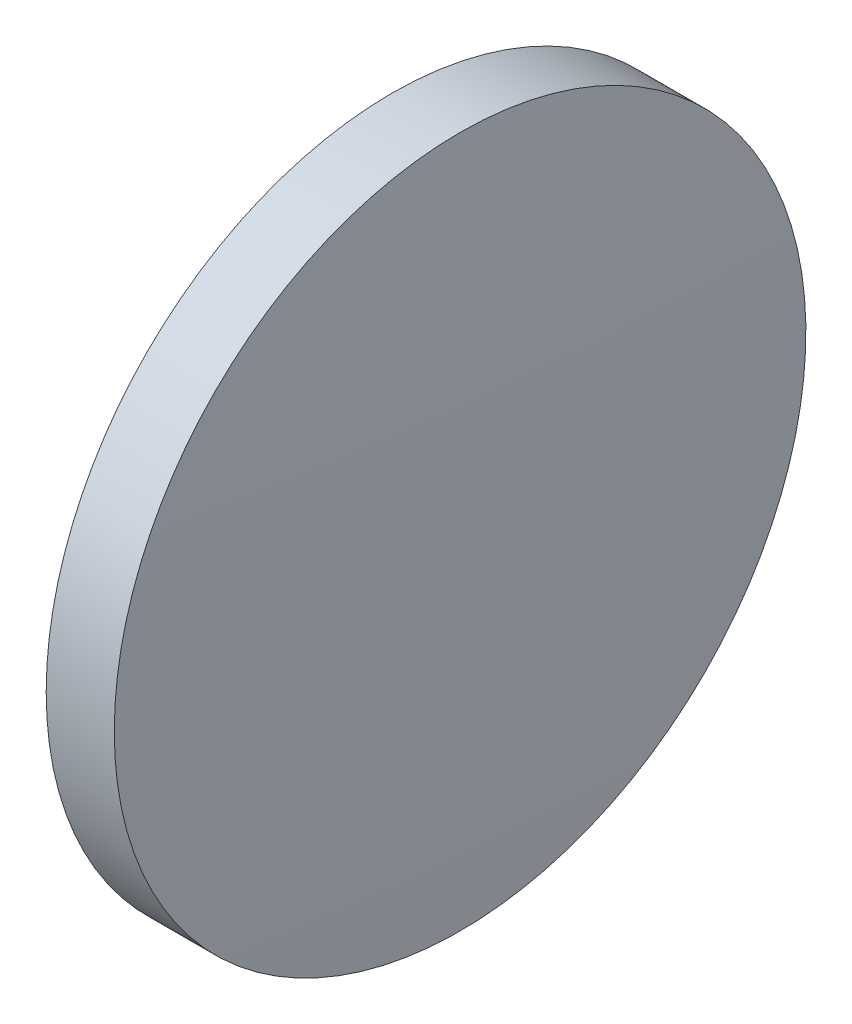
from build123d import *

# Parameters (mm, degrees)
SKETCH_1_ONE_SIDE_W = 2.499998629
SKETCH_1_ONE_SIDE_H = 12.7


with BuildPart() as part:
    # 草图1 one side → 旋转1 (revolve)
    with BuildSketch(Plane.XY):
        with Locations((86.458193775, 54.966113023)):
            Rectangle(SKETCH_1_ONE_SIDE_W, SKETCH_1_ONE_SIDE_H)
        with BuildLine():
            Line((84.913235962, 48.616113023), (85.20819446, 48.616113023))
            Line((85.20819446, 48.616113023), (85.20819446, 61.316113023))
            ThreePointArc((85.20819446, 61.316113023), (84.986985528, 54.967825401), (84.913235962, 48.616113023))
        make_face()
        with BuildLine():
            Line((87.708193089, 48.616113023), (88.003151587, 48.616113023))
            ThreePointArc((88.003151587, 48.616113023), (87.929402021, 54.967825401), (87.708193089, 61.316113023))
            Line((87.708193089, 61.316113023), (87.708193089, 48.616113023))
        make_face()
    revolve(axis=Axis((83.371981052, 48.616113023, 0), (1, 0, 0)))


solid = part.part
